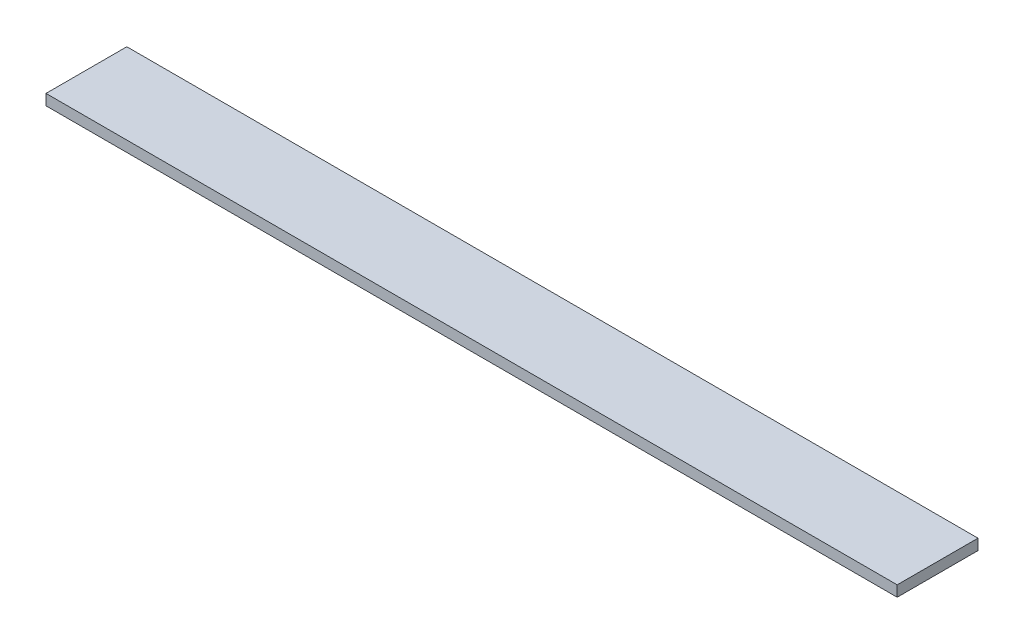
from build123d import *

# Parameters (mm, degrees)
SKETCH_1_W      = 30
SKETCH_1_H      = 4
EXTRUDE_1_DEPTH = 316


with BuildPart() as part:
    # Эскиз1 → Бобышка-Вытянуть1 (new body)
    with BuildSketch(Plane(origin=(0, 0, 0), x_dir=(0, 0, -1), z_dir=(1, 0, 0))):
        Rectangle(SKETCH_1_W, SKETCH_1_H)
    extrude(amount=EXTRUDE_1_DEPTH)


solid = part.part
